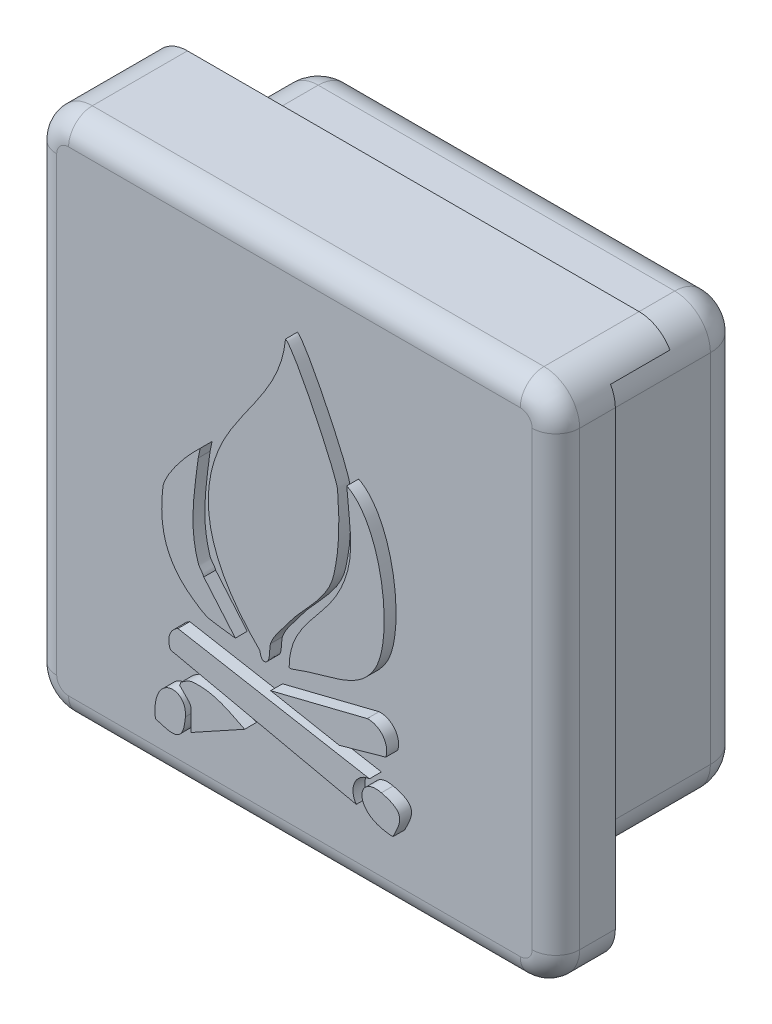
from build123d import *

# Parameters (mm, degrees)
ESQUISSE2_W             = 44
ESQUISSE2_H             = 44
BOSS_EXTRU_1_DEPTH      = 10
ESQUISSE3_W             = 36
ESQUISSE3_H             = 36
BOSS_EXTRU_2_DEPTH      = 10
ESQUISSE4_W             = 42.5
ESQUISSE4_H             = 42.5
ESQUISSE4_W_2           = 36
ESQUISSE4_H_2           = 36
ENL_V_MAT_EXTRU_1_DEPTH = 5
CONG_1_R                = 3
CONG_2_R                = 2
BOSS_EXTRU_4_DEPTH      = 1


with BuildPart() as part:
    # Esquisse2 → Boss.-Extru.1 (new body)
    with BuildSketch(Plane.XY):
        with Locations((22, 22)):
            Rectangle(ESQUISSE2_W, ESQUISSE2_H)
    extrude(amount=BOSS_EXTRU_1_DEPTH)

    # Esquisse3 → Boss.-Extru.2 (add)
    with BuildSketch(Plane(origin=(0, 0, 0), x_dir=(-1, 0, 0), z_dir=(0, 0, -1))):
        with Locations((-22, 22)):
            Rectangle(ESQUISSE3_W, ESQUISSE3_H)
    extrude(amount=BOSS_EXTRU_2_DEPTH)

    # Esquisse4 → Enlèv. mat.-Extru.1 (cut)
    with BuildSketch(Plane(origin=(0, 0, 0), x_dir=(-1, 0, 0), z_dir=(0, 0, -1))):
        with Locations((-22.75, 21.25)):
            Rectangle(ESQUISSE4_W, ESQUISSE4_H)
        with Locations((-22, 22)):
            Rectangle(ESQUISSE4_W_2, ESQUISSE4_H_2, mode=Mode.SUBTRACT)
    extrude(amount=-ENL_V_MAT_EXTRU_1_DEPTH, mode=Mode.SUBTRACT)

    # Congé1
    cong_1_edges = [part.edges().sort_by_distance(p)[0] for p in [
        (22, 40, -10),
        (4, 22, -10),
        (22, 4, -10),
        (40, 22, -10),
        (44, 0, 7.5),
        (44, 44, 5),
        (0, 0, 5),
        (0, 44, 5),
        (1.5, 42.5, 2.5),
        (4, 4, -2.5),
        (4, 40, -2.5),
        (40, 4, -2.5),
        (40, 40, -2.5),
    ]]
    fillet(cong_1_edges, radius=CONG_1_R)

    # Congé2
    cong_2_edges = [part.edges().sort_by_distance(p)[0] for p in [
        (44, 22, 10),
        (22, 0, 10),
        (0, 22, 10),
        (22, 44, 10),
        (0.878679656, 43.121320344, 10),
        (0.878679656, 0.878679656, 10),
        (43.121320344, 43.121320344, 10),
        (43.121320344, 0.878679656, 10),
    ]]
    fillet(cong_2_edges, radius=CONG_2_R)

    # Esquisse7 → Boss.-Extru.4 (add)
    with BuildSketch(Plane.XY.offset(10)):
        with BuildLine():
            Line((15.374098957, 17.346843443), (18.030348957, 14.221843443))
            add(Edge.make_bspline(
                [(18.030348957, 14.221843443), (17.301182291, 14.32601011), (16.565114838, 14.389890267), (15.842848957, 14.534343443), (15.423010802, 14.618311074), (14.838115665, 15.028795794), (14.436598957, 15.315593443), (12.049681404, 17.020534553), (11.595795075, 19.293760446), (11.936598957, 22.190593443), (12.054157826, 23.189843826), (13.69238751, 25.196381996), (14.436598957, 25.940593443)],
                knots=[0, 0, 0, 0, 1, 1, 1, 2, 2, 2, 3, 3, 3, 4, 4, 4, 4], degree=3))
            Line((14.436598957, 25.940593443), (15.06939707, 26.573391556))
            Line((15.06939707, 26.573391556), (14.905348957, 25.784343443))
            add(Edge.make_bspline(
                [(14.905348957, 25.784343443), (14.590446041, 23.265120116), (14.091309116, 20.570212966), (14.905348957, 18.128093443), (15.001385879, 17.839982679), (15.278062036, 17.634954207), (15.374098957, 17.346843443)],
                knots=[0, 0, 0, 0, 1, 1, 1, 2, 2, 2, 2], degree=3))
        make_face()
        with BuildLine():
            Line((30.686598957, 11.878093443), (26.780348957, 10.784343443))
            Line((26.780348957, 10.784343443), (20.999098957, 11.878093443))
            Line((20.999098957, 11.878093443), (29.124098957, 13.909343443))
            ThreePointArc((29.124098957, 13.909343443), (30.444920086, 13.308773157), (30.686598957, 11.878093443))
        make_face()
        with BuildLine():
            Line((18.811598957, 7.971843443), (14.280348957, 5.471843443))
            add(Edge.make_bspline(
                [(14.280348957, 5.471843443), (14.280348957, 7.772797666), (14.593726557, 7.189715843), (13.342848957, 8.440593443)],
                knots=[0, 0, 0, 0, 1, 1, 1, 1], degree=3))
            add(Edge.make_bspline(
                [(13.342848957, 8.440593443), (13.394932291, 8.54476011), (13.404330032, 8.685401354), (13.499098957, 8.753093443), (13.783405732, 8.956169711), (14.089133052, 9.185268084), (14.436598957, 9.221843443), (16.134694919, 9.400590386), (17.384797269, 8.685244287), (18.811598957, 7.971843443)],
                knots=[0, 0, 0, 0, 1, 1, 1, 2, 2, 2, 3, 3, 3, 3], degree=3))
        make_face()
        with BuildLine():
            Line((13.200641117, 12.506283222), (29.317230938, 9.618393711))
            ThreePointArc((29.317230938, 9.618393711), (28.067553161, 8.724486443), (28.200641117, 7.193783222))
            Line((28.200641117, 7.193783222), (12.575641117, 10.631283222))
            ThreePointArc((12.575641117, 10.631283222), (12.499815902, 11.698224961), (13.200641117, 12.506283222))
        make_face()
        with BuildLine():
            add(Edge.make_bspline(
                [(20.999098957, 15.315593443), (20.827145061, 14.799731755), (21.046210645, 13.925047339), (20.530348957, 13.753093443), (20.153128088, 13.627353153), (20.137873233, 14.301819167), (20.061598957, 14.378093443), (16.567694762, 17.871997638), (14.613515541, 21.933204334), (16.467848957, 26.878093443), (17.971713728, 30.888399498), (21.846423142, 33.698659479), (22.249098957, 38.128093443)],
                knots=[4, 4, 4, 4, 5, 5, 5, 6, 6, 6, 7, 7, 7, 8, 8, 8, 8], degree=3))
            add(Edge.make_bspline(
                [(22.249098957, 38.128093443), (23.024720103, 37.74028287), (26.549972992, 30.317022339), (26.624098957, 29.378093443), (26.824723104, 26.836854256), (26.793735434, 25.141457588), (26.311598957, 22.971843443), (25.843661476, 20.866124777), (23.763276375, 19.341691827), (22.561598957, 17.659343443), (22.093633816, 17.004192245), (21.257183639, 16.089847489), (20.999098957, 15.315593443)],
                knots=[0, 0, 0, 0, 1, 1, 1, 2, 2, 2, 3, 3, 3, 4, 4, 4, 4], degree=3))
        make_face()
        with BuildLine():
            add(Edge.make_bspline(
                [(22.874098957, 14.378093443), (22.776875457, 14.340699789), (22.561598957, 14.273926776), (22.561598957, 14.378093443), (22.561598957, 17.724570677), (25.385181625, 19.244008778), (26.780348957, 22.034343443), (28.269529967, 25.012705463), (27.627114524, 26.898375507), (27.405348957, 30.003093443)],
                knots=[3, 3, 3, 3, 4, 4, 4, 5, 5, 5, 6, 6, 6, 6], degree=3))
            add(Edge.make_bspline(
                [(27.405348957, 30.003093443), (30.439237099, 28.486149372), (31.410808057, 20.585108609), (29.749098957, 17.815593443), (28.578255605, 15.864187855), (26.718288261, 15.58655694), (24.749098957, 15.003093443), (24.117435238, 14.815933822), (23.488994366, 14.614591677), (22.874098957, 14.378093443)],
                knots=[0, 0, 0, 0, 1, 1, 1, 2, 2, 2, 3, 3, 3, 3], degree=3))
        make_face()
        with BuildLine():
            add(Edge.make_bspline(
                [(13.825641117, 6.383595142), (13.664946359, 4.294397314), (12.835062605, 4.491118619), (11.307669526, 4.983380758)],
                knots=[1, 1, 1, 1, 2, 2, 2, 2], degree=3))
            add(Edge.make_bspline(
                [(11.307669526, 4.983380758), (10.888236852, 8.443524348), (13.995704046, 8.594588879), (13.825641117, 6.383595142)],
                knots=[0, 0, 0, 0, 1, 1, 1, 1], degree=3))
        make_face()
        with BuildLine():
            add(Edge.make_bspline(
                [(30.312986898, 9.093826211), (32.34922339, 8.599547626), (32.02172038, 7.812052803), (31.290447284, 6.383595142)],
                knots=[1, 1, 1, 1, 2, 2, 2, 2], degree=3))
            add(Edge.make_bspline(
                [(31.290447284, 6.383595142), (27.807867011, 6.525553152), (28.158042034, 9.616920214), (30.312986898, 9.093826211)],
                knots=[0, 0, 0, 0, 1, 1, 1, 1], degree=3))
        make_face()
    extrude(amount=BOSS_EXTRU_4_DEPTH)


solid = part.part
